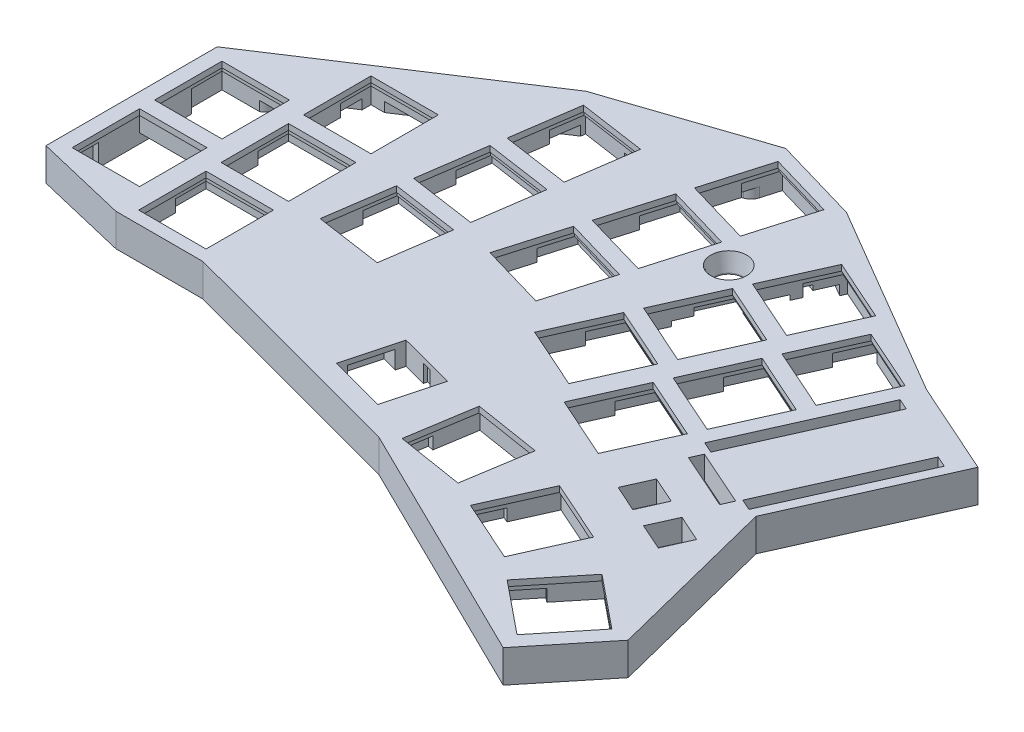
from build123d import *

# Parameters (mm, degrees)
LAYOUT_BASED_ON_OG_W     = 13.9
LAYOUT_BASED_ON_OG_H     = 13.9
LAYOUT_BASED_ON_OG_R     = 3
TOP_PLATE_DEPTH          = 1.2
BOSS_EXTRUDE2_START      = -5.5
LAYOUT_BASED_ON_OG_7_R   = 1
LAYOUT_BASED_ON_OG_7_W   = 13.9
LAYOUT_BASED_ON_OG_7_H   = 13.9
LAYOUT_BASED_ON_OG_7_R_2 = 3
BOSS_EXTRUDE2_DEPTH      = 5.5
SKETCH1_W                = 14.7
SKETCH1_H                = 14.7
CUT_EXTRUDE1_DEPTH       = 5.5
CUT_EXTRUDE2_DEPTH       = 5.7
SKETCH5_W                = 17
SKETCH5_H                = 7.4
CUT_EXTRUDE3_DEPTH       = 4.5
CUT_EXTRUDE4_DEPTH       = 2.2
SKETCH8_R                = 2.5
SKETCH8_R_2              = 2.25
CUT_EXTRUDE5_DEPTH       = 2
FILLET1_R                = 1.5
CUT_EXTRUDE6_DEPTH       = 1
CHAMFER1_SIZE            = 0.7
CHAMFER1_SIZE2           = 3.5
CUT_EXTRUDE7_DEPTH       = 4


with BuildPart() as part:
    # Layout Based on OG → Top Plate (new body)
    with BuildSketch(Plane(origin=(0, 0, 0), x_dir=(1, 0, 0), z_dir=(0, 1, 0))):
        Polygon((44.932112641, 64.586160661), (-1, 34.518088786), (-1, -0.789622065), (17.882445607, -5.291259199), (35.868672805, -5.291259199), (85.361540778, -18.518913408), (135.758281381, -43.294373445), (147.28611756, -29.083818781), (138.36478836, 6.221102631), (152.486966257, 37.866376671), (133.367786474, 46.398597243), (93.420652892, 69.813076074), (75.723768858, 74.969568789), align=None)
        with Locations((9, 8.5)):
            Rectangle(LAYOUT_BASED_ON_OG_W, LAYOUT_BASED_ON_OG_H, mode=Mode.SUBTRACT)
        with Locations((27, 4.208740801)):
            Rectangle(LAYOUT_BASED_ON_OG_W, LAYOUT_BASED_ON_OG_H, mode=Mode.SUBTRACT)
        Polygon((82.42671831, -1.483486994), (79.405763835, -12.786753516), (67.812669966, -9.68833867), (70.833624441, 1.614927852), align=None, mode=Mode.SUBTRACT)
        Polygon((124.073654328, -30.793104213), (132.830543438, -19.998341913), (143.625305738, -28.755231024), (134.868416628, -39.549993323), align=None, mode=Mode.SUBTRACT)
        Polygon((106.968309305, -21.25715678), (112.632924584, -8.563767408), (125.326313955, -14.228382687), (119.661698676, -26.921772059), align=None, mode=Mode.SUBTRACT)
        Polygon((87.98288219, -16.369909233), (90.169189468, -2.642926298), (103.896172402, -4.829233576), (101.709865125, -18.55621651), align=None, mode=Mode.SUBTRACT)
        Polygon((103.849381672, 19.547250989), (116.542771044, 13.88263571), (110.878155765, 1.189246339), (98.184766393, 6.853861618), align=None, mode=Mode.SUBTRACT)
        Polygon((124.470413663, -5.2830693), (118.991252783, -2.837911626), (121.436410458, 2.641249254), (126.915571338, 0.19609158), align=None, mode=Mode.SUBTRACT)
        Polygon((133.940230051, -9.509116814), (128.461069171, -7.06395914), (130.906226845, -1.58479826), (136.385387725, -4.029955934), align=None, mode=Mode.SUBTRACT)
        Polygon((132.530478518, 4.557765216), (120.932921322, 9.73334896), (121.95173702, 12.01633266), (133.549294215, 6.840748916), align=None, mode=Mode.SUBTRACT)
        with Locations((9, 25.5)):
            Rectangle(LAYOUT_BASED_ON_OG_W, LAYOUT_BASED_ON_OG_H, mode=Mode.SUBTRACT)
        with Locations((27, 21.208740801)):
            Rectangle(LAYOUT_BASED_ON_OG_W, LAYOUT_BASED_ON_OG_H, mode=Mode.SUBTRACT)
        with Locations((27, 38.208740801)):
            Rectangle(LAYOUT_BASED_ON_OG_W, LAYOUT_BASED_ON_OG_H, mode=Mode.SUBTRACT)
        Polygon((40.2890512, 14.443567583), (42.28500861, 28.199517351), (56.040958378, 26.20355994), (54.045000968, 12.447610172), align=None, mode=Mode.SUBTRACT)
        Polygon((63.880386081, 25.872461201), (67.768842672, 39.217494185), (81.113875656, 35.329037594), (77.225419065, 21.98400461), align=None, mode=Mode.SUBTRACT)
        Polygon((42.730150191, 31.26739104), (44.726107602, 45.023340808), (58.48205737, 43.027383397), (56.486099959, 29.271433629), align=None, mode=Mode.SUBTRACT)
        Polygon((45.171249182, 48.091214497), (47.167206593, 61.847164265), (60.923156361, 59.851206854), (58.92719895, 46.095257086), align=None, mode=Mode.SUBTRACT)
        Polygon((88.345576683, 28.974928579), (101.038966054, 23.310313301), (95.374350775, 10.616923929), (82.680961404, 16.281539208), align=None, mode=Mode.SUBTRACT)
        Polygon((95.273523427, 44.499217739), (107.966912798, 38.83460246), (102.302297519, 26.141213088), (89.608908148, 31.805828367), align=None, mode=Mode.SUBTRACT)
        Polygon((110.777328416, 35.071540149), (123.470717788, 29.40692487), (117.806102509, 16.713535498), (105.112713137, 22.378150777), align=None, mode=Mode.SUBTRACT)
        Polygon((122.242660591, 13.036314755), (119.959676891, 14.055130453), (132.389228402, 41.907531592), (134.672212102, 40.888715895), align=None, mode=Mode.SUBTRACT)
        Polygon((148.826711042, 34.572058569), (136.39715953, 6.71965743), (134.11417583, 7.738473128), (146.543727342, 35.590874267), align=None, mode=Mode.SUBTRACT)
        Polygon((112.040659882, 37.902439937), (117.70527516, 50.595829308), (130.398664532, 44.93121403), (124.734049253, 32.237824658), align=None, mode=Mode.SUBTRACT)
        Polygon((72.524509006, 55.538757546), (85.86954199, 51.650300955), (81.981085399, 38.305267971), (68.636052415, 42.193724562), align=None, mode=Mode.SUBTRACT)
        with Locations((90.749335526, 48.215544602)):
            Circle(LAYOUT_BASED_ON_OG_R, mode=Mode.SUBTRACT)
        Polygon((96.536854892, 47.330117527), (102.201470171, 60.023506899), (114.894859542, 54.35889162), (109.230244263, 41.665502248), align=None, mode=Mode.SUBTRACT)
        Polygon((73.391718749, 58.514987924), (77.280175341, 71.860020908), (90.625208324, 67.971564317), (86.736751733, 54.626531333), align=None, mode=Mode.SUBTRACT)
    extrude(amount=TOP_PLATE_DEPTH)

    # Layout Based on OG_7 → Boss-Extrude2 (add)
    with BuildSketch(Plane(origin=(0, 0, 0), x_dir=(1, 0, 0), z_dir=(0, 1, 0)).offset(BOSS_EXTRUDE2_START)):
        Polygon((44.932112641, 64.586160661), (-1, 34.518088786), (-1, -0.789622065), (17.882445607, -5.291259199), (35.868672805, -5.291259199), (85.361540778, -18.518913408), (135.758281381, -43.294373445), (147.28611756, -29.083818781), (138.36478836, 6.221102631), (152.486966257, 37.866376671), (133.367786474, 46.398597243), (93.420652892, 69.813076074), (75.723768858, 74.969568789), align=None)
        with Locations((16.2, -1.806082572)):
            Circle(LAYOUT_BASED_ON_OG_7_R, mode=Mode.SUBTRACT)
        with Locations((9, 8.5)):
            Rectangle(LAYOUT_BASED_ON_OG_7_W, LAYOUT_BASED_ON_OG_7_H, mode=Mode.SUBTRACT)
        with Locations((27, 4.208740801)):
            Rectangle(LAYOUT_BASED_ON_OG_7_W, LAYOUT_BASED_ON_OG_7_H, mode=Mode.SUBTRACT)
        Polygon((82.42671831, -1.483486994), (79.405763835, -12.786753516), (67.812669966, -9.68833867), (70.833624441, 1.614927852), align=None, mode=Mode.SUBTRACT)
        with Locations((99.12368379, -21.941578986)):
            Circle(LAYOUT_BASED_ON_OG_7_R, mode=Mode.SUBTRACT)
        Polygon((124.073654328, -30.793104213), (132.830543438, -19.998341913), (143.625305738, -28.755231024), (134.868416628, -39.549993323), align=None, mode=Mode.SUBTRACT)
        Polygon((106.968309305, -21.25715678), (112.632924584, -8.563767408), (125.326313955, -14.228382687), (119.661698676, -26.921772059), align=None, mode=Mode.SUBTRACT)
        with Locations((142.657712264, -23.012806408)):
            Circle(LAYOUT_BASED_ON_OG_7_R, mode=Mode.SUBTRACT)
        Polygon((87.98288219, -16.369909233), (90.169189468, -2.642926298), (103.896172402, -4.829233576), (101.709865125, -18.55621651), align=None, mode=Mode.SUBTRACT)
        Polygon((103.849381672, 19.547250989), (116.542771044, 13.88263571), (110.878155765, 1.189246339), (98.184766393, 6.853861618), align=None, mode=Mode.SUBTRACT)
        Polygon((124.470413663, -5.2830693), (118.991252783, -2.837911626), (121.436410458, 2.641249254), (126.915571338, 0.19609158), align=None, mode=Mode.SUBTRACT)
        Polygon((133.940230051, -9.509116814), (128.461069171, -7.06395914), (130.906226845, -1.58479826), (136.385387725, -4.029955934), align=None, mode=Mode.SUBTRACT)
        Polygon((132.530478518, 4.557765216), (120.932921322, 9.73334896), (121.95173702, 12.01633266), (133.549294215, 6.840748916), align=None, mode=Mode.SUBTRACT)
        with Locations((9, 25.5)):
            Rectangle(LAYOUT_BASED_ON_OG_7_W, LAYOUT_BASED_ON_OG_7_H, mode=Mode.SUBTRACT)
        with Locations((27, 21.208740801)):
            Rectangle(LAYOUT_BASED_ON_OG_7_W, LAYOUT_BASED_ON_OG_7_H, mode=Mode.SUBTRACT)
        with Locations((7.046718387, 36.2)):
            Circle(LAYOUT_BASED_ON_OG_7_R, mode=Mode.SUBTRACT)
        with Locations((27, 38.208740801)):
            Rectangle(LAYOUT_BASED_ON_OG_7_W, LAYOUT_BASED_ON_OG_7_H, mode=Mode.SUBTRACT)
        Polygon((40.2890512, 14.443567583), (42.28500861, 28.199517351), (56.040958378, 26.20355994), (54.045000968, 12.447610172), align=None, mode=Mode.SUBTRACT)
        Polygon((63.880386081, 25.872461201), (67.768842672, 39.217494185), (81.113875656, 35.329037594), (77.225419065, 21.98400461), align=None, mode=Mode.SUBTRACT)
        Polygon((42.730150191, 31.26739104), (44.726107602, 45.023340808), (58.48205737, 43.027383397), (56.486099959, 29.271433629), align=None, mode=Mode.SUBTRACT)
        Polygon((45.171249182, 48.091214497), (47.167206593, 61.847164265), (60.923156361, 59.851206854), (58.92719895, 46.095257086), align=None, mode=Mode.SUBTRACT)
        with Locations((72.753454085, 70.801954714)):
            Circle(LAYOUT_BASED_ON_OG_7_R, mode=Mode.SUBTRACT)
        Polygon((88.345576683, 28.974928579), (101.038966054, 23.310313301), (95.374350775, 10.616923929), (82.680961404, 16.281539208), align=None, mode=Mode.SUBTRACT)
        Polygon((95.273523427, 44.499217739), (107.966912798, 38.83460246), (102.302297519, 26.141213088), (89.608908148, 31.805828367), align=None, mode=Mode.SUBTRACT)
        Polygon((110.777328416, 35.071540149), (123.470717788, 29.40692487), (117.806102509, 16.713535498), (105.112713137, 22.378150777), align=None, mode=Mode.SUBTRACT)
        Polygon((122.242660591, 13.036314755), (119.959676891, 14.055130453), (132.389228402, 41.907531592), (134.672212102, 40.888715895), align=None, mode=Mode.SUBTRACT)
        Polygon((148.826711042, 34.572058569), (136.39715953, 6.71965743), (134.11417583, 7.738473128), (146.543727342, 35.590874267), align=None, mode=Mode.SUBTRACT)
        Polygon((112.040659882, 37.902439937), (117.70527516, 50.595829308), (130.398664532, 44.93121403), (124.734049253, 32.237824658), align=None, mode=Mode.SUBTRACT)
        with Locations((144.64373469, 38.081361754)):
            Circle(LAYOUT_BASED_ON_OG_7_R, mode=Mode.SUBTRACT)
        Polygon((72.524509006, 55.538757546), (85.86954199, 51.650300955), (81.981085399, 38.305267971), (68.636052415, 42.193724562), align=None, mode=Mode.SUBTRACT)
        with Locations((90.749335526, 48.215544602)):
            Circle(LAYOUT_BASED_ON_OG_7_R_2, mode=Mode.SUBTRACT)
        Polygon((96.536854892, 47.330117527), (102.201470171, 60.023506899), (114.894859542, 54.35889162), (109.230244263, 41.665502248), align=None, mode=Mode.SUBTRACT)
        Polygon((73.391718749, 58.514987924), (77.280175341, 71.860020908), (90.625208324, 67.971564317), (86.736751733, 54.626531333), align=None, mode=Mode.SUBTRACT)
    extrude(amount=BOSS_EXTRUDE2_DEPTH)

    # Sketch1 → Cut-Extrude1 (cut)
    with BuildSketch(Plane.XZ):
        Polygon((124.936316134, -31.709536754), (130.926952436, -45.13348091), (117.50300828, -51.124117212), (111.512371978, -37.700173056), align=None)
        Polygon((118.00836939, -16.185247595), (123.999005692, -29.60919175), (110.575061536, -35.599828052), (104.584425234, -22.175883897), align=None)
        Polygon((111.080422646, -0.660958435), (117.071058948, -14.084902591), (103.647114792, -20.075538893), (97.65647849, -6.651594737), align=None)
        Polygon((95.576617656, -10.088636025), (101.567253958, -23.512580181), (88.143309802, -29.503216483), (82.1526735, -16.079272327), align=None)
        Polygon((102.5045644, -25.612925185), (108.495200702, -39.036869341), (95.071256546, -45.027505643), (89.080620244, -31.603561487), align=None)
        Polygon((109.432511144, -41.137214344), (115.423147446, -54.5611585), (101.99920329, -60.551794802), (96.008566988, -47.127850647), align=None)
        Polygon((119.863965557, 27.450059962), (125.854601859, 14.026115807), (112.430657703, 8.035479505), (106.440021401, 21.45942366), align=None)
        Polygon((144.187943189, 28.696587191), (134.927060461, 40.112630774), (123.511016877, 30.851748046), (132.771899605, 19.435704463), align=None)
        Polygon((104.354108811, 4.497127801), (102.041970899, 19.014152919), (87.524945781, 16.702015007), (89.837083693, 2.184989889), align=None)
        Polygon((86.365469748, -51.92243265), (82.253217094, -37.809340214), (68.140124658, -41.921592868), (72.252377311, -56.034685304), align=None)
        Polygon((91.121136082, -68.243696011), (87.008883428, -54.130603575), (72.895790992, -58.242856229), (77.008043646, -72.355948665), align=None)
        Polygon((61.376448654, -60.189623901), (59.265615997, -45.641964794), (44.71795689, -47.752797451), (46.828789547, -62.300456558), align=None)
        with Locations((27, -38.208740801)):
            Rectangle(SKETCH1_W, SKETCH1_H)
        Polygon((81.609803413, -35.601169288), (77.497550759, -21.488076852), (63.384458323, -25.600329506), (67.496710977, -39.713421942), align=None)
        Polygon((58.935349662, -43.365800443), (56.824517005, -28.818141336), (42.276857898, -30.928973994), (44.387690555, -45.476633101), align=None)
        Polygon((56.494250671, -26.541976986), (54.383418014, -11.994317879), (39.835758907, -14.105150536), (41.946591564, -28.652809644), align=None)
        with Locations((27, -21.208740801)):
            Rectangle(SKETCH1_W, SKETCH1_H)
        with Locations((27, -4.208740801)):
            Rectangle(SKETCH1_W, SKETCH1_H)
        with Locations((9, -8.5)):
            Rectangle(SKETCH1_W, SKETCH1_H)
        with Locations((9, -25.5)):
            Rectangle(SKETCH1_W, SKETCH1_H)
    extrude(amount=CUT_EXTRUDE1_DEPTH, mode=Mode.SUBTRACT)

    # Sketch4 → Cut-Extrude2 (cut)
    with BuildSketch(Plane.XZ.offset(5.5)):
        Polygon((75.052980345, 9.708478692), (74.381657128, 12.220315697), (72.449474817, 11.703913223), (73.120798034, 9.192076218), align=None)
        Polygon((83.02323238, 11.838638899), (75.052980345, 9.708478692), (77.118590243, 1.979749446), (85.088842277, 4.109909653), align=None)
        Polygon((77.789913459, -0.532087558), (77.118590243, 1.979749446), (75.186407931, 1.463346972), (75.857731148, -1.048490033), align=None)
        Polygon((75.186407931, 1.463346972), (73.120798034, 9.192076218), (65.150545999, 7.061916011), (67.216155897, -0.666813235), align=None)
    extrude(amount=-CUT_EXTRUDE2_DEPTH, mode=Mode.SUBTRACT)

    # Sketch5 → Cut-Extrude3 (cut)
    with BuildSketch(Plane.XZ.offset(5.5)):
        Polygon((90.476814804, -61.9215247), (92.546928385, -69.026074634), (76.225665023, -73.781740968), (74.155551443, -66.677191034), align=None)
        Polygon((80.965482135, -29.278997977), (83.035595716, -36.383547911), (66.714332355, -41.139214245), (64.644218774, -34.034664311), align=None)
        Polygon((85.72114847, -45.600261338), (87.79126205, -52.704811272), (71.469998689, -57.460477607), (69.399885108, -50.355927673), align=None)
        Polygon((113.926280704, -48.385044029), (116.941975169, -55.142675781), (101.417686009, -62.070622525), (98.401991544, -55.312990773), align=None)
        Polygon((106.99833396, -32.86075487), (110.014028425, -39.618386622), (94.489739265, -46.546333366), (91.4740448, -39.788701614), align=None)
        Polygon((100.070387216, -17.33646571), (103.086081681, -24.094097462), (87.561792521, -31.022044206), (84.546098056, -24.264412454), align=None)
        Polygon((115.574192206, -7.90878812), (118.589886671, -14.666419872), (103.065597511, -21.594366616), (100.049903046, -14.836734864), align=None)
        Polygon((122.50213895, -23.433077279), (125.517833415, -30.190709031), (109.993544255, -37.118655775), (106.97784979, -30.361024024), align=None)
        Polygon((129.430085694, -38.957366439), (132.445780159, -45.714998191), (116.921490999, -52.642944935), (113.905796534, -45.885313183), align=None)
        Polygon((61.617067964, -53.839261521), (62.679663996, -61.162572909), (45.855840539, -63.6036719), (44.793244507, -56.280360513), align=None)
        Polygon((59.175968973, -37.015438064), (60.238565005, -44.338749451), (43.414741547, -46.779848443), (42.352145516, -39.456537055), align=None)
        Polygon((56.734869982, -20.191614607), (57.797466013, -27.514925994), (40.973642556, -29.956024986), (39.911046525, -22.632713598), align=None)
        with Locations((27, -43.008740801)):
            Rectangle(SKETCH5_W, SKETCH5_H)
        with Locations((27, -26.008740801)):
            Rectangle(SKETCH5_W, SKETCH5_H)
        with Locations((9, -30.3)):
            Rectangle(SKETCH5_W, SKETCH5_H)
        with Locations((9, -3.7)):
            Rectangle(SKETCH5_W, SKETCH5_H)
        with Locations((27, -9.008740801)):
            Rectangle(SKETCH5_W, SKETCH5_H)
        Polygon((120.445482838, 28.968887685), (123.461177303, 22.211255933), (107.936888143, 15.283309189), (104.921193678, 22.040940941), align=None)
        Polygon((102.996775, 20.330720095), (104.160708371, 13.0228299), (87.372311976, 10.348928913), (86.208378605, 17.656819108), align=None)
        Polygon((135.09566148, 41.730213445), (139.757602445, 35.983361573), (126.555375172, 25.273497193), (121.893434207, 31.020349065), align=None)
    extrude(amount=-CUT_EXTRUDE3_DEPTH, mode=Mode.SUBTRACT)

    # Sketch6 → Cut-Extrude4 (cut)
    with BuildSketch(Plane.XZ.offset(5.5)):
        Polygon((137.298581205, 4.437482213), (129.993033365, 1.177271981), (127.547875691, 6.656432861), (134.853423531, 9.916643093), align=None)
        Polygon((125.383607143, 5.690595579), (127.828764818, 0.211434699), (120.523216978, -3.048775533), (118.078059304, 2.430385347), align=None)
    extrude(amount=-CUT_EXTRUDE4_DEPTH, mode=Mode.SUBTRACT)

    # Sketch8 → Cut-Extrude5 (cut)
    with BuildSketch(Plane.XZ.offset(5.5)):
        with BuildLine():
            Line((139.204412223, 23.173053982), (142.654833761, 18.919662182))
            Line((142.654833761, 18.919662182), (136.255917661, -6.403159671))
            Line((136.255917661, -6.403159671), (148.826711042, -34.572058569))
            Line((148.826711042, -34.572058569), (146.543727342, -35.590874267))
            ThreePointArc((146.543727342, -35.590874267), (143.36716228, -35.220791377), (141.521163202, -37.832268802))
            Line((141.521163202, -37.832268802), (131.019438182, -42.518821011))
            Line((131.019438182, -42.518821011), (116.921490999, -52.642944935))
            Line((116.921490999, -52.642944935), (116.434522933, -54.005566109))
            Line((116.434522933, -54.005566109), (100.910233773, -60.933512853))
            Line((100.910233773, -60.933512853), (91.752890515, -66.300967302))
            Line((91.752890515, -66.300967302), (75.431627153, -71.056633637))
            Line((75.431627153, -71.056633637), (75.153639873, -70.102592018))
            ThreePointArc((75.153639873, -70.102592018), (74.557701937, -69.071437541), (73.552294547, -68.433019528))
            Line((73.552294547, -68.433019528), (55.20726644, -62.246801008))
            Line((55.20726644, -62.246801008), (45.727060034, -62.716128839))
            Line((45.727060034, -62.716128839), (21.274106965, -46.708740801))
            Line((21.274106965, -46.708740801), (18.5, -44.892755365))
            Line((18.5, -44.892755365), (8.416074326, -38.291617631))
            ThreePointArc((8.416074326, -38.291617631), (9.544475268, -36.094120052), (8.234152595, -34))
            Line((8.234152595, -34), (1.65, -34))
            Line((1.65, -34), (1.65, -32.85))
            Line((1.65, -32.85), (1.65, -0.634659927))
            Line((1.65, -0.634659927), (19.65, -0.634659927))
            Line((19.65, -0.634659927), (34.35, 3.141259199))
            Line((34.35, 3.141259199), (35.570084054, 3.141259199))
            Line((35.570084054, 3.141259199), (86.358362209, 16.715129715))
            Line((86.358362209, 16.715129715), (100.642371929, 19.955732482))
            ThreePointArc((100.642371929, 19.955732482), (101.622918455, 21.879723566), (100.738750735, 23.849865852))
            Line((100.738750735, 23.849865852), (131.997484899, 39.216921535))
            Line((131.997484899, 39.216921535), (138.479921397, 24.066145827))
            Line((138.479921397, 24.066145827), (139.204412223, 23.173053982))
        make_face()
        with Locations((136.661892762, -29.397342614)):
            Circle(SKETCH8_R, mode=Mode.SUBTRACT)
        with Locations((131.696592578, -18.270993254)):
            Circle(SKETCH8_R, mode=Mode.SUBTRACT)
        with Locations((109.591444293, 3.388071472)):
            Circle(SKETCH8_R_2, mode=Mode.SUBTRACT)
        with BuildLine():
            Line((130.503779674, 9.848098828), (124.686737206, 7.25215643))
            ThreePointArc((124.686737206, 7.25215643), (122.045297688, 8.263490832), (123.05663209, 10.90493035))
            Line((123.05663209, 10.90493035), (128.873674557, 13.500872748))
            ThreePointArc((128.873674557, 13.500872748), (131.515114075, 12.489538346), (130.503779674, 9.848098828))
        make_face(mode=Mode.SUBTRACT)
        with BuildLine():
            Line((86.814692561, -8.729855258), (63.028921107, -15.086932))
            ThreePointArc((63.028921107, -15.086932), (59.968190125, -13.317207203), (61.737914921, -10.256476221))
            Line((61.737914921, -10.256476221), (85.523686375, -3.899399479))
            ThreePointArc((85.523686375, -3.899399479), (88.584417357, -5.669124275), (86.814692561, -8.729855258))
        make_face(mode=Mode.SUBTRACT)
        with BuildLine():
            Line((64.970718214, -56.485039592), (62.537305637, -45.272693234))
            ThreePointArc((62.537305637, -45.272693234), (63.685041764, -43.488680403), (65.469054595, -44.63641653))
            Line((65.469054595, -44.63641653), (67.902467172, -55.848762888))
            ThreePointArc((67.902467172, -55.848762888), (66.754731045, -57.632775719), (64.970718214, -56.485039592))
        make_face(mode=Mode.SUBTRACT)
        with BuildLine():
            Line((38.423692073, -53.453161546), (37.944396883, -46.816793128))
            ThreePointArc((37.944396883, -46.816793128), (39.332447725, -45.212637631), (40.936603222, -46.600688473))
            Line((40.936603222, -46.600688473), (41.415898413, -53.237056891))
            ThreePointArc((41.415898413, -53.237056891), (40.027847571, -54.841212388), (38.423692073, -53.453161546))
        make_face(mode=Mode.SUBTRACT)
    extrude(amount=-CUT_EXTRUDE5_DEPTH, mode=Mode.SUBTRACT)

    # Fillet1
    fillet1_edges = [part.edges().sort_by_distance(p)[0] for p in [
        (38.184044478, -3.5, -50.134977337),
        (40.027847571, -3.5, -54.841212388),
        (41.176250818, -3.5, -49.918872682),
        (39.332447725, -3.5, -45.212637631),
        (63.685041764, -3.5, -43.488680403),
        (66.685760884, -3.5, -50.242589709),
        (63.754011925, -3.5, -50.878866413),
        (66.754731045, -3.5, -57.632775719),
        (74.921806834, -3.5, -11.908393629),
        (88.584417357, -3.5, -5.669124275),
        (59.968190125, -3.5, -13.317207203),
        (73.630800648, -3.5, -7.07793785),
        (127.59525844, -3.5, 8.550127629),
        (131.515114075, -3.5, 12.489538346),
        (125.965153324, -3.5, 12.202901549),
        (122.045297688, -3.5, 8.263490832),
        (107.341444293, -3.5, 3.388071472),
        (134.161892762, -3.5, -29.397342614),
        (129.196592578, -3.5, -18.270993254),
    ]]
    fillet(fillet1_edges, radius=FILLET1_R)

    # Sketch9 → Cut-Extrude6 (cut)
    with BuildSketch(Plane.XZ.offset(3.5)):
        Polygon((92.272615366, -35.673430804), (81.476293661, -39.634420283), (89.226055687, -60.757658401), (100.022377391, -56.796668921), align=None)
    extrude(amount=-CUT_EXTRUDE6_DEPTH, mode=Mode.SUBTRACT)

    # Chamfer1
    chamfer1_edges = [part.edges().sort_by_distance(p)[0] for p in [
        (87.749335526, 1.2, -48.215544602),
    ]]
    chamfer1_side = [part.faces().sort_by_distance(p)[0] for p in [
        (81.179535673, 1.2, -18.788906196),
    ]]
    chamfer(chamfer1_edges, length=CHAMFER1_SIZE, length2=CHAMFER1_SIZE2, reference=chamfer1_side[0])

    # Sketch11 → Cut-Extrude7 (cut)
    with BuildSketch(Plane.XZ.offset(3.5)):
        Polygon((61.654545258, 10.112692603), (66.04396629, -6.310857044), (39.959505086, -13.282290448), (35.570084054, 3.141259199), align=None)
    extrude(amount=-CUT_EXTRUDE7_DEPTH, mode=Mode.SUBTRACT)


solid = part.part
